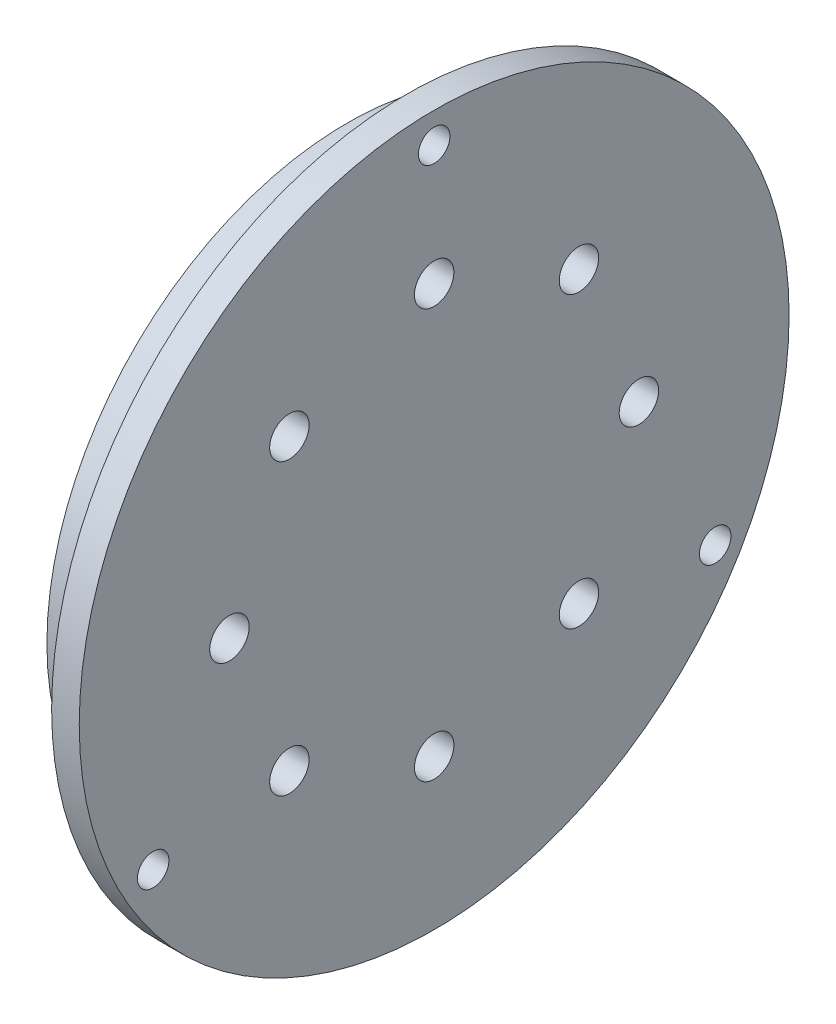
from build123d import *

# Parameters (mm, degrees)
SKETCH2_R          = 4
CUT_EXTRUDE1_DEPTH = 10
CIRPATTERN1_COUNT  = 3
SKETCH3_R          = 5
CUT_EXTRUDE2_DEPTH = 130.16655914
CIRPATTERN2_COUNT  = 8


with BuildPart() as part:
    # Sketch1 → Revolve1 (revolve)
    with BuildSketch(Plane.XY):
        Polygon((0, 0), (0, 76.2), (5.475419526, 76.2), (5.475419526, 72.846582988), (9.822609824, 72.846582988), (9.822609824, 76.2), (15, 76.2), (15, 90), (22, 90), (22, 0), align=None)
    revolve(axis=Axis((22, 0, 0), (-1, 0, 0)))

    # Sketch2 → Cut-Extrude1 (cut)
    with BuildSketch(Plane.ZY.offset(-15)):
        with Locations((0, 82.277326688)):
            Circle(SKETCH2_R)
    cut_extrude1 = extrude(amount=-CUT_EXTRUDE1_DEPTH, mode=Mode.SUBTRACT)

    # CirPattern1: Cut-Extrude1 ×3 about axis
    cirpattern1_axis = Axis((-80.9, 0, 0), (1, 0, 0))
    for i in range(1, CIRPATTERN1_COUNT):
        add(cut_extrude1.rotate(cirpattern1_axis, i * 360 / CIRPATTERN1_COUNT), mode=Mode.SUBTRACT)

    # Sketch3 → Cut-Extrude2 (cut, through all)
    with BuildSketch(Plane.ZY):
        with Locations((0, 51.916670562)):
            Circle(SKETCH3_R)
    cut_extrude2 = extrude(amount=-CUT_EXTRUDE2_DEPTH, mode=Mode.SUBTRACT)

    # CirPattern2: Cut-Extrude2 ×8 about axis
    cirpattern2_axis = Axis((-80.9, 0, 0), (1, 0, 0))
    for i in range(1, CIRPATTERN2_COUNT):
        add(cut_extrude2.rotate(cirpattern2_axis, i * 360 / CIRPATTERN2_COUNT), mode=Mode.SUBTRACT)


solid = part.part
